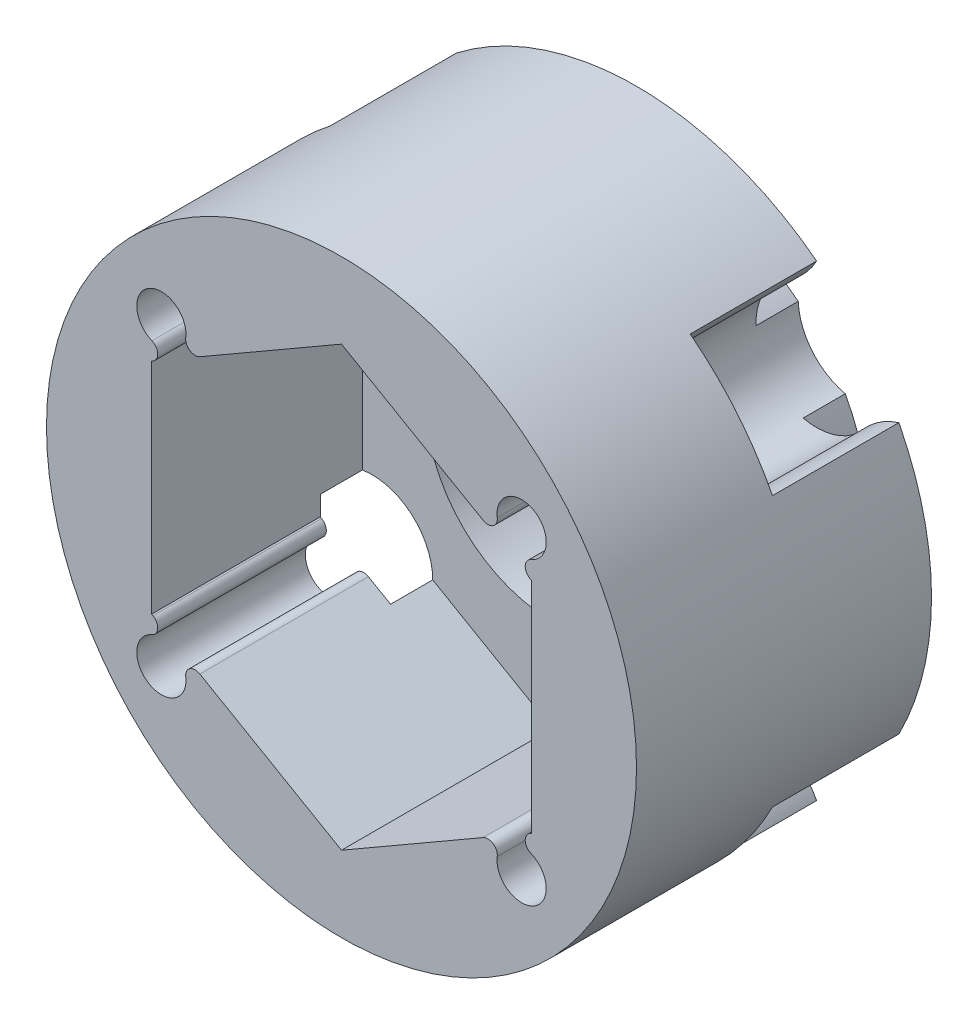
from build123d import *

# Parameters (mm, degrees)
SKETCH1_R               = 7
BOSS_EXTRUDE1_DEPTH     = 7
SKETCH4_R               = 3
BOSS_EXTRUDE2_DEPTH     = 1
CUT_EXTRUDE4_START      = -3
CUT_EXTRUDE4_DEPTH      = 3
CUT_EXTRUDE5_DEPTH      = 5
CUT_EXTRUDE6_DEPTH      = 5
CUT_EXTRUDE7_DEPTH      = 13.124355653
CUT_EXTRUDE7_DEPTH_BACK = 13.124355653
SKETCH4_4_R             = 3


with BuildPart() as part:
    # Sketch1 → Boss-Extrude1 (new body)
    with BuildSketch(Plane.XY):
        Circle(SKETCH1_R)
    extrude(amount=-BOSS_EXTRUDE1_DEPTH)

    # Sketch4 → Boss-Extrude2 (add)
    with BuildSketch(Plane(origin=(0, 0, -7), x_dir=(-1, 0, 0), z_dir=(0, 0, -1))):
        with BuildLine():
            ThreePointArc((2.837096154, 3.497268279), (0, 4.5033321), (-2.837096154, 3.497268279))
            ThreePointArc((-2.837096154, 3.497268279), (-3.168771964, 2.638481586), (-3.953282021, 2.156747845))
            ThreePointArc((-3.953282021, 2.156747845), (-4.5033321, 0), (-3.953282021, -2.156747845))
            ThreePointArc((-3.953282021, -2.156747845), (-3.168771964, -2.638481586), (-2.837096154, -3.497268279))
            ThreePointArc((-2.837096154, -3.497268279), (0, -4.5033321), (2.837096154, -3.497268279))
            ThreePointArc((2.837096154, -3.497268279), (3.168771964, -2.638481586), (3.953282021, -2.156747845))
            ThreePointArc((3.953282021, -2.156747845), (4.5033321, 0), (3.953282021, 2.156747845))
            ThreePointArc((3.953282021, 2.156747845), (3.168771964, 2.638481586), (2.837096154, 3.497268279))
        make_face()
        Circle(SKETCH4_R, mode=Mode.SUBTRACT)
    extrude(amount=BOSS_EXTRUDE2_DEPTH)

    # Sketch4_3 → Cut-Extrude4 (cut)
    with BuildSketch(Plane(origin=(0, 0, -7), x_dir=(-1, 0, 0), z_dir=(0, 0, -1)).offset(CUT_EXTRUDE4_START)):
        with BuildLine():
            ThreePointArc((4.274062643, 5.543680052), (3.977849472, 5.135421007), (3.583758725, 4.820603323))
            ThreePointArc((3.583758725, 4.820603323), (3.168771964, 2.638481586), (5.389966001, 2.651378794))
            ThreePointArc((5.389966001, 2.651378794), (5.770954662, 2.981931862), (6.226111662, 3.199302046))
            ThreePointArc((6.226111662, 3.199302046), (5.379353322, 4.479124673), (4.274062643, 5.543680052))
        make_face()
        with BuildLine():
            ThreePointArc((-3.583758725, 4.820603323), (-3.977849472, 5.135421007), (-4.274062643, 5.543680052))
            ThreePointArc((-4.274062643, 5.543680052), (-5.379353322, 4.479124673), (-6.226111662, 3.199302046))
            ThreePointArc((-6.226111662, 3.199302046), (-5.770954662, 2.981931862), (-5.389966001, 2.651378794))
            ThreePointArc((-5.389966001, 2.651378794), (-3.168771964, 2.638481586), (-3.583758725, 4.820603323))
        make_face()
        with BuildLine():
            ThreePointArc((3.583758725, -4.820603323), (3.977849472, -5.135421007), (4.274062643, -5.543680052))
            ThreePointArc((4.274062643, -5.543680052), (5.379353322, -4.479124673), (6.226111662, -3.199302046))
            ThreePointArc((6.226111662, -3.199302046), (5.770954662, -2.981931862), (5.389966001, -2.651378794))
            ThreePointArc((5.389966001, -2.651378794), (3.168771964, -2.638481586), (3.583758725, -4.820603323))
        make_face()
        with BuildLine():
            ThreePointArc((-5.389966001, -2.651378794), (-5.770954662, -2.981931862), (-6.226111662, -3.199302046))
            ThreePointArc((-6.226111662, -3.199302046), (-5.379353322, -4.479124673), (-4.274062643, -5.543680052))
            ThreePointArc((-4.274062643, -5.543680052), (-3.977849472, -5.135421007), (-3.583758725, -4.820603323))
            ThreePointArc((-3.583758725, -4.820603323), (-3.168771964, -2.638481586), (-5.389966001, -2.651378794))
        make_face()
    extrude(amount=CUT_EXTRUDE4_DEPTH, mode=Mode.SUBTRACT)

    # Sketch1_5 → Cut-Extrude5 (cut)
    with BuildSketch(Plane.XY):
        Polygon((-3.360638375, -3.259734529), (0, -5.2), (3.360638375, -3.259734529), (4.471773772, -2.618220209), (4.5033321, -2.6), (4.5033321, 2.6), (4.471773772, 2.618220209), (3.360638375, 3.259734529), (0, 5.2), (-3.360638375, 3.259734529), (-4.471773772, 2.618220209), (-4.5033321, 2.6), (-4.5033321, -2.6), (-4.471773772, -2.618220209), align=None)
    extrude(amount=-CUT_EXTRUDE5_DEPTH, mode=Mode.SUBTRACT)

    # Sketch1_6 → Cut-Extrude6 (cut)
    with BuildSketch(Plane.XY):
        with BuildLine():
            Line((4.471773772, -2.618220209), (3.360638375, -3.259734529))
            ThreePointArc((3.360638375, -3.259734529), (3.597609587, -3.267426216), (3.695640854, -3.483306711))
            ThreePointArc((3.695640854, -3.483306711), (4.565726609, -4.063979936), (4.497891721, -3.020126957))
            ThreePointArc((4.497891721, -3.020126957), (4.359949362, -2.827289142), (4.471773772, -2.618220209))
        make_face()
        with BuildLine():
            ThreePointArc((-3.695640854, -3.483306711), (-3.597609587, -3.267426216), (-3.360638375, -3.259734529))
            Line((-3.360638375, -3.259734529), (-4.471773772, -2.618220209))
            ThreePointArc((-4.471773772, -2.618220209), (-4.359949362, -2.827289142), (-4.497891721, -3.020126957))
            ThreePointArc((-4.497891721, -3.020126957), (-4.565726609, -4.063979936), (-3.695640854, -3.483306711))
        make_face()
        with BuildLine():
            Line((3.360638375, 3.259734529), (4.471773772, 2.618220209))
            ThreePointArc((4.471773772, 2.618220209), (4.359949362, 2.827289142), (4.497891721, 3.020126957))
            ThreePointArc((4.497891721, 3.020126957), (4.565726609, 4.063979936), (3.695640854, 3.483306711))
            ThreePointArc((3.695640854, 3.483306711), (3.597609587, 3.267426216), (3.360638375, 3.259734529))
        make_face()
        with BuildLine():
            ThreePointArc((-4.497891721, 3.020126957), (-4.359949362, 2.827289142), (-4.471773772, 2.618220209))
            Line((-4.471773772, 2.618220209), (-3.360638375, 3.259734529))
            ThreePointArc((-3.360638375, 3.259734529), (-3.597609587, 3.267426216), (-3.695640854, 3.483306711))
            ThreePointArc((-3.695640854, 3.483306711), (-4.565726609, 4.063979936), (-4.497891721, 3.020126957))
        make_face()
    extrude(amount=-CUT_EXTRUDE6_DEPTH, mode=Mode.SUBTRACT)

    # Sketch4_4 → Cut-Extrude7 (cut, two sides: drawn at the far end of the back side and taken through both)
    with BuildSketch(Plane(origin=(0, 0, -7), x_dir=(-1, 0, 0), z_dir=(0, 0, -1)).offset(-CUT_EXTRUDE7_DEPTH_BACK)):
        Circle(SKETCH4_4_R)
    extrude(amount=CUT_EXTRUDE7_DEPTH + CUT_EXTRUDE7_DEPTH_BACK, mode=Mode.SUBTRACT)


solid = part.part
